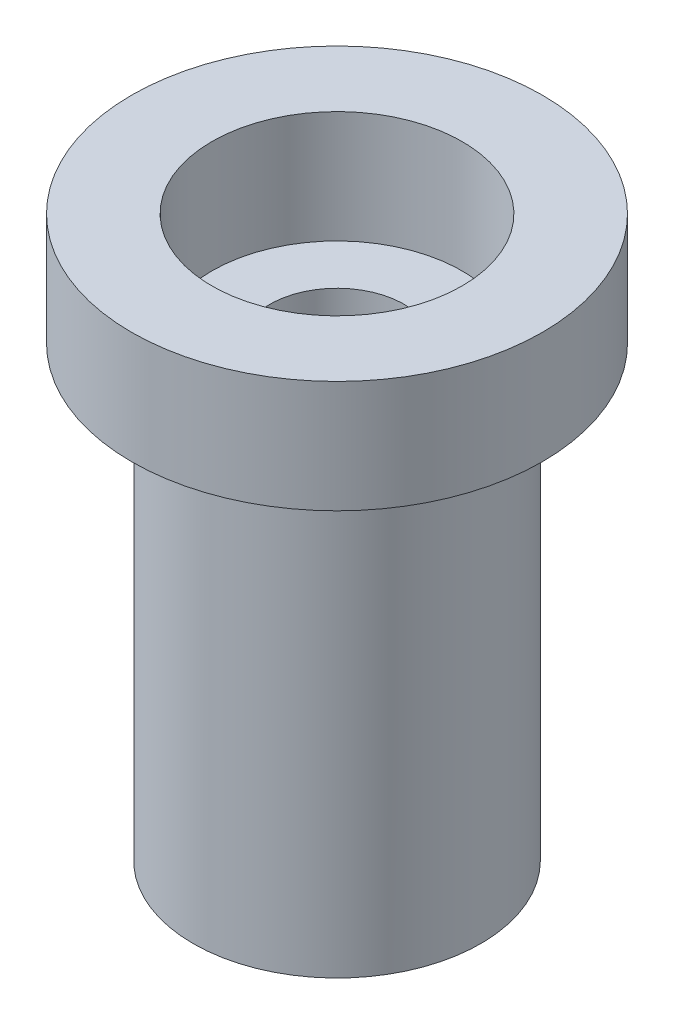
from build123d import *

# Parameters (mm, degrees)
SKETCH1_R           = 3.85
SKETCH1_R_2         = 1.8
BOSS_EXTRUDE1_DEPTH = 12
SKETCH2_R           = 5.5
SKETCH2_R_2         = 3.35
BOSS_EXTRUDE2_DEPTH = 3


with BuildPart() as part:
    # Sketch1 → Boss-Extrude1 (new body)
    with BuildSketch(Plane(origin=(0, 0, 0), x_dir=(1, 0, 0), z_dir=(0, 1, 0))):
        Circle(SKETCH1_R)
        Circle(SKETCH1_R_2, mode=Mode.SUBTRACT)
    extrude(amount=BOSS_EXTRUDE1_DEPTH)

    # Sketch2 → Boss-Extrude2 (add)
    with BuildSketch(Plane(origin=(0, 12, 0), x_dir=(1, 0, 0), z_dir=(0, 1, 0))):
        Circle(SKETCH2_R)
        Circle(SKETCH2_R_2, mode=Mode.SUBTRACT)
    extrude(amount=BOSS_EXTRUDE2_DEPTH)


solid = part.part
